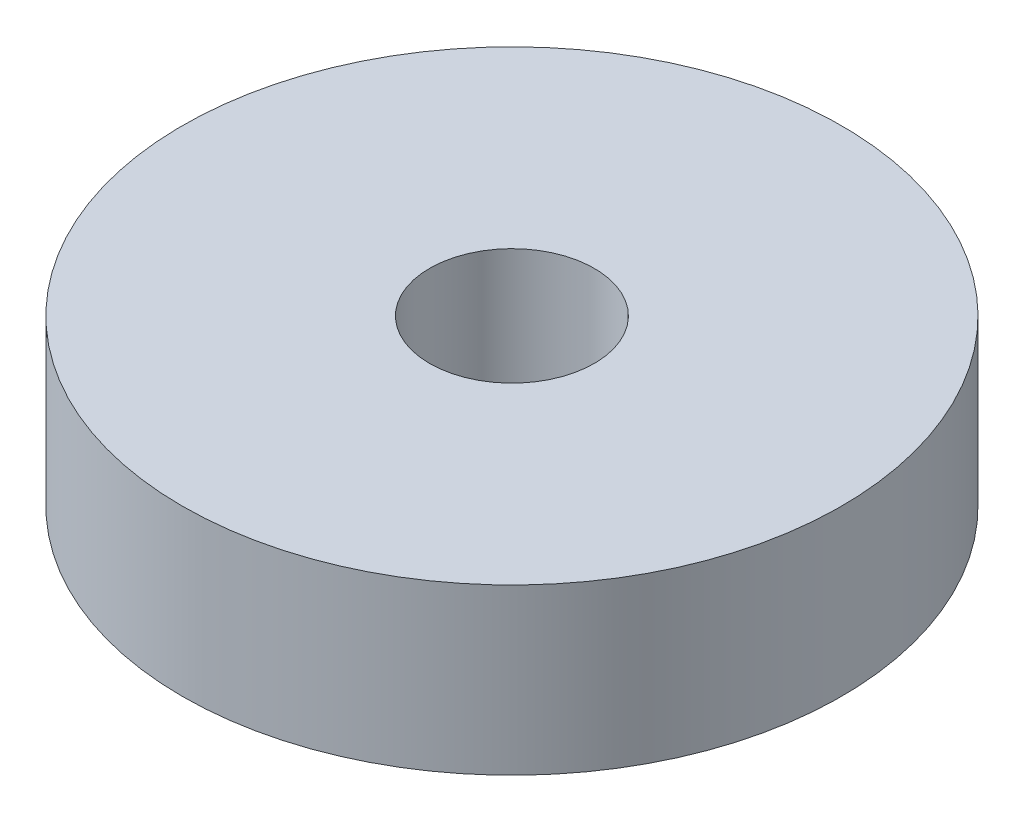
from build123d import *

# Parameters (mm, degrees)
SKETCH1_R           = 6
SKETCH1_R_2         = 1.5
BOSS_EXTRUDE1_DEPTH = 3


with BuildPart() as part:
    # Sketch1 → Boss-Extrude1 (new body)
    with BuildSketch(Plane(origin=(0, 0, 0), x_dir=(1, 0, 0), z_dir=(0, 1, 0))):
        Circle(SKETCH1_R)
        Circle(SKETCH1_R_2, mode=Mode.SUBTRACT)
    extrude(amount=BOSS_EXTRUDE1_DEPTH)


solid = part.part
